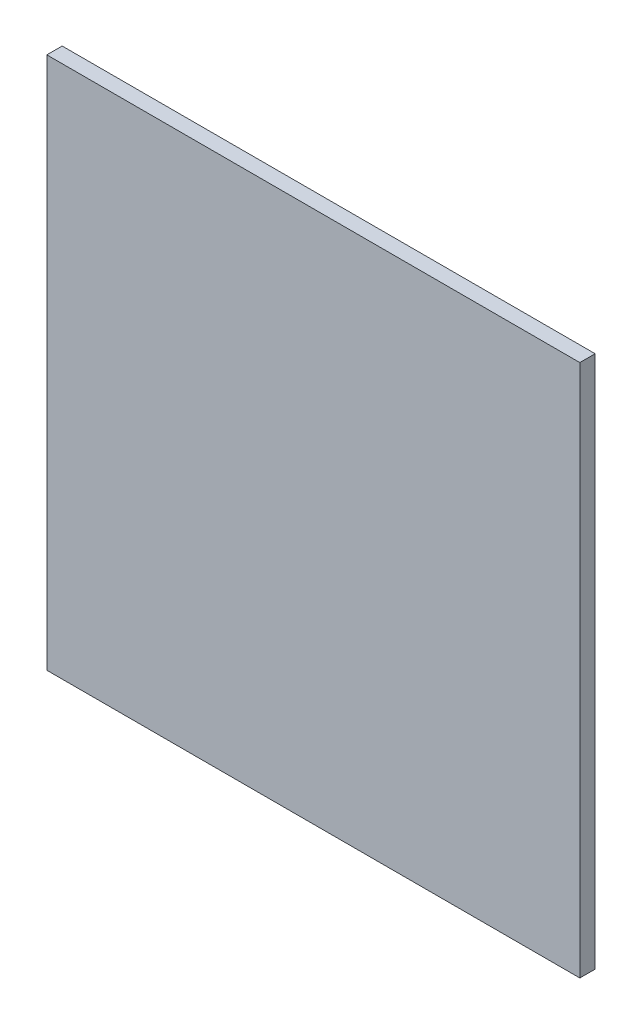
from build123d import *

# Parameters (mm, degrees)
SKETCH1_W           = 160
SKETCH1_H           = 160
BOSS_EXTRUDE1_DEPTH = 4.6


with BuildPart() as part:
    # Sketch1 → Boss-Extrude1 (new body)
    with BuildSketch(Plane.XY):
        with Locations((-10.999068873, -294.405681156)):
            Rectangle(SKETCH1_W, SKETCH1_H)
    extrude(amount=BOSS_EXTRUDE1_DEPTH)


solid = part.part
